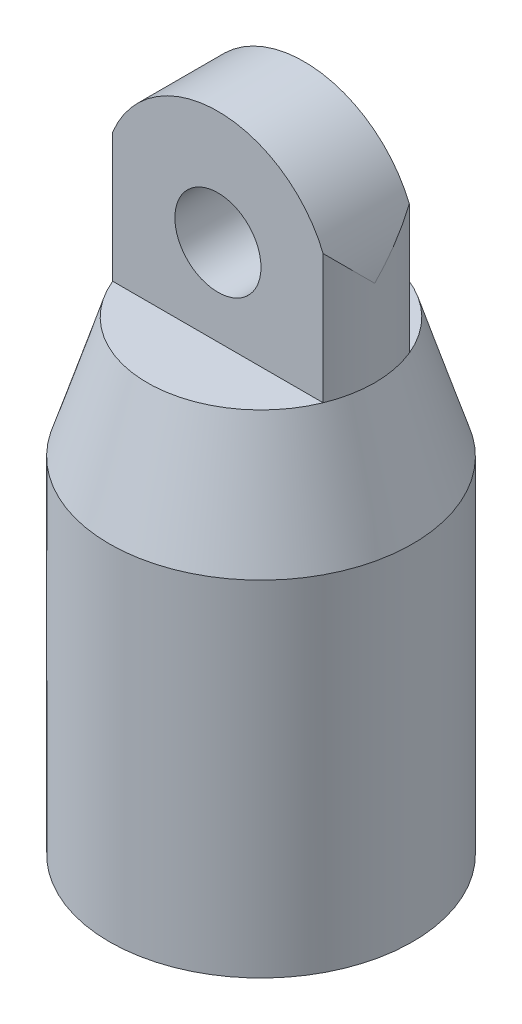
from build123d import *

# Parameters (mm, degrees)
SKETCH1_R           = 5.588
SKETCH1_R_2         = 4.572
BOSS_EXTRUDE1_DEPTH = 12.7
SKETCH3_R           = 1.5875
BOSS_EXTRUDE3_DEPTH = 1.5875
SKETCH6_OUTSIDE_W   = 19.008
SKETCH6_OUTSIDE_H   = 19.008
SKETCH6_OUTSIDE_R   = 4.191
CUT_EXTRUDE4_DEPTH  = 25.4


with BuildPart() as part:
    # Sketch1 → Boss-Extrude1 (new body)
    with BuildSketch(Plane(origin=(0, 0, 0), x_dir=(1, 0, 0), z_dir=(0, 1, 0))):
        Circle(SKETCH1_R)
        Circle(SKETCH1_R_2, mode=Mode.SUBTRACT)
    extrude(amount=BOSS_EXTRUDE1_DEPTH)

    # Sketch2 → Revolve2 (revolve)
    with BuildSketch(Plane.XY):
        Polygon((-5.588, 12.7), (-4.572, 12.7), (-2.159, 15.113), (0, 15.113), (0, 17.145), (-2.159, 17.145), (-4.191, 17.145), align=None)
    revolve(axis=Axis((0, 15.113, 0), (0, 1, 0)))

    # Sketch3 → Boss-Extrude3 (add, symmetric)
    with BuildSketch(Plane.XY):
        with BuildLine():
            Line((-4.191, 17.145), (4.191, 17.145))
            Line((4.191, 17.145), (4.191, 20.32))
            ThreePointArc((4.191, 20.32), (0, 24.511), (-4.191, 20.32))
            Line((-4.191, 20.32), (-4.191, 17.145))
        make_face()
        with Locations((0, 20.32)):
            Circle(SKETCH3_R, mode=Mode.SUBTRACT)
    extrude(amount=BOSS_EXTRUDE3_DEPTH, both=True)

    # Sketch6 outside → Cut-Extrude4 (cut)
    with BuildSketch(Plane.XZ.offset(-17.145)):
        Rectangle(SKETCH6_OUTSIDE_W, SKETCH6_OUTSIDE_H)
        Circle(SKETCH6_OUTSIDE_R, mode=Mode.SUBTRACT)
    extrude(amount=-CUT_EXTRUDE4_DEPTH, mode=Mode.SUBTRACT)


solid = part.part
